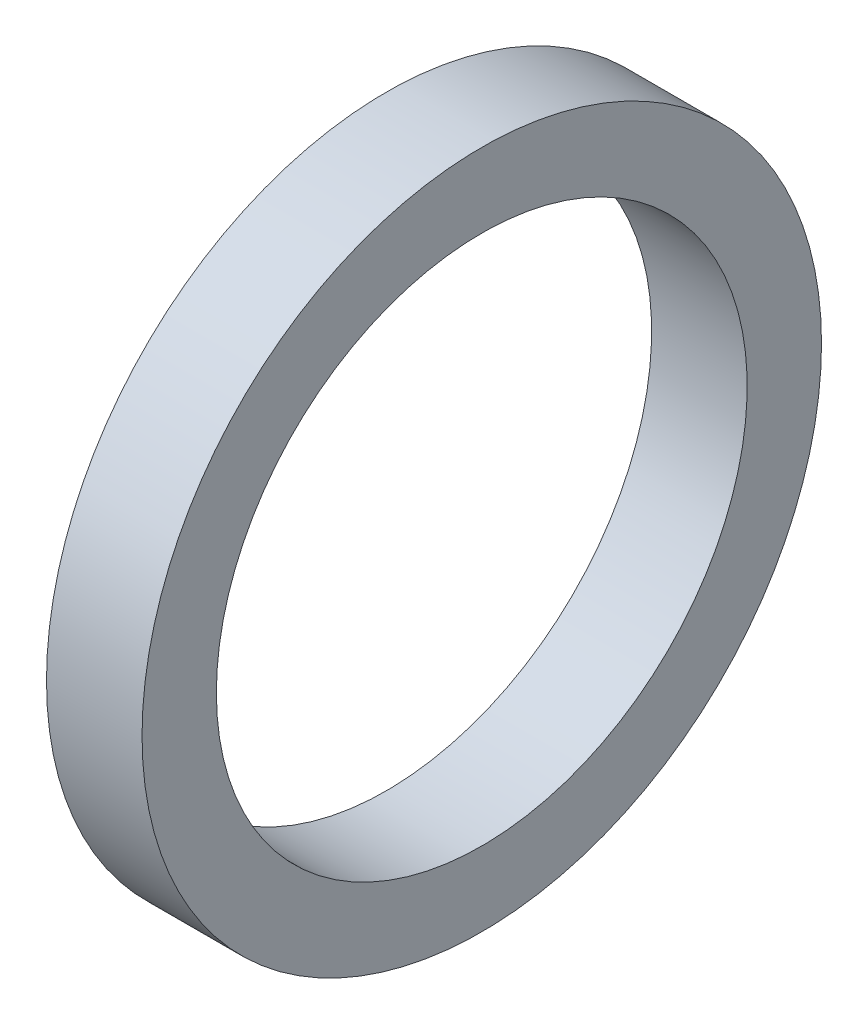
from build123d import *

# Parameters (mm, degrees)
SKIZZE1_W = 4.5
SKIZZE1_H = 3.5


with BuildPart() as part:
    # Skizze1 → Rotation1 (revolve)
    with BuildSketch(Plane.XY):
        with Locations((-0.25, 14.25)):
            Rectangle(SKIZZE1_W, SKIZZE1_H)
    revolve(axis=Axis((-5.638304677, 0, 0), (1, 0, 0)))


solid = part.part
